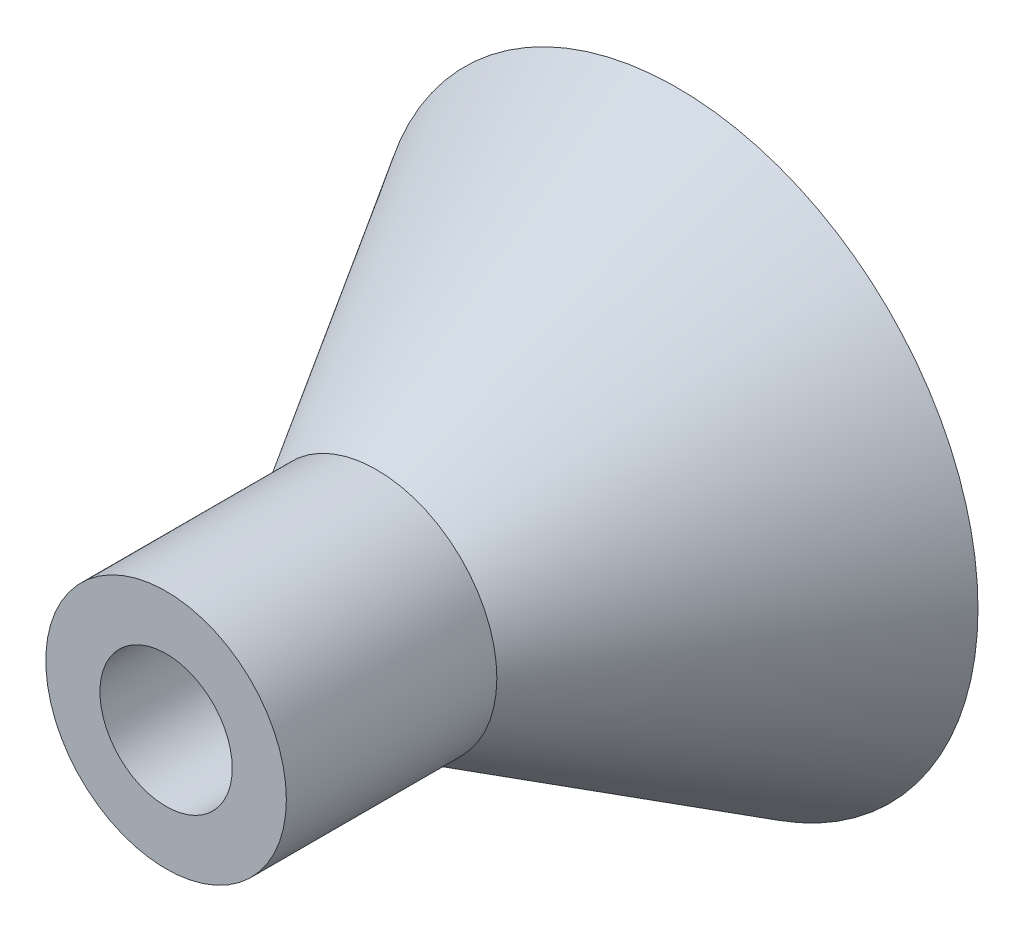
from build123d import *

# Parameters (mm, degrees)
SKETCH1_R           = 10
BOSS_EXTRUDE1_DEPTH = 10
SKETCH3_R           = 4
BOSS_EXTRUDE2_DEPTH = 7
SKETCH4_R           = 2.2
CUT_EXTRUDE1_DEPTH  = 18


with BuildPart() as part:
    # Sketch1 → Boss-Extrude1 (new body)
    with BuildSketch(Plane.XY):
        Circle(SKETCH1_R)
    extrude(amount=BOSS_EXTRUDE1_DEPTH)

    # Sketch2 → Cut-Revolve2 (revolve, cut)
    with BuildSketch(Plane(origin=(0, 0, 0), x_dir=(0, 0, -1), z_dir=(1, 0, 0))):
        Polygon((0, -10), (-10, -4), (-10, -10), align=None)
    revolve(axis=Axis((0, 0, 10), (0, 0, -1)), mode=Mode.SUBTRACT)

    # Sketch3 → Boss-Extrude2 (add)
    with BuildSketch(Plane.XY.offset(10)):
        Circle(SKETCH3_R)
    extrude(amount=BOSS_EXTRUDE2_DEPTH)

    # Sketch4 → Cut-Extrude1 (cut, through all)
    with BuildSketch(Plane.XY.offset(17)):
        Circle(SKETCH4_R)
    extrude(amount=-CUT_EXTRUDE1_DEPTH, mode=Mode.SUBTRACT)


solid = part.part
